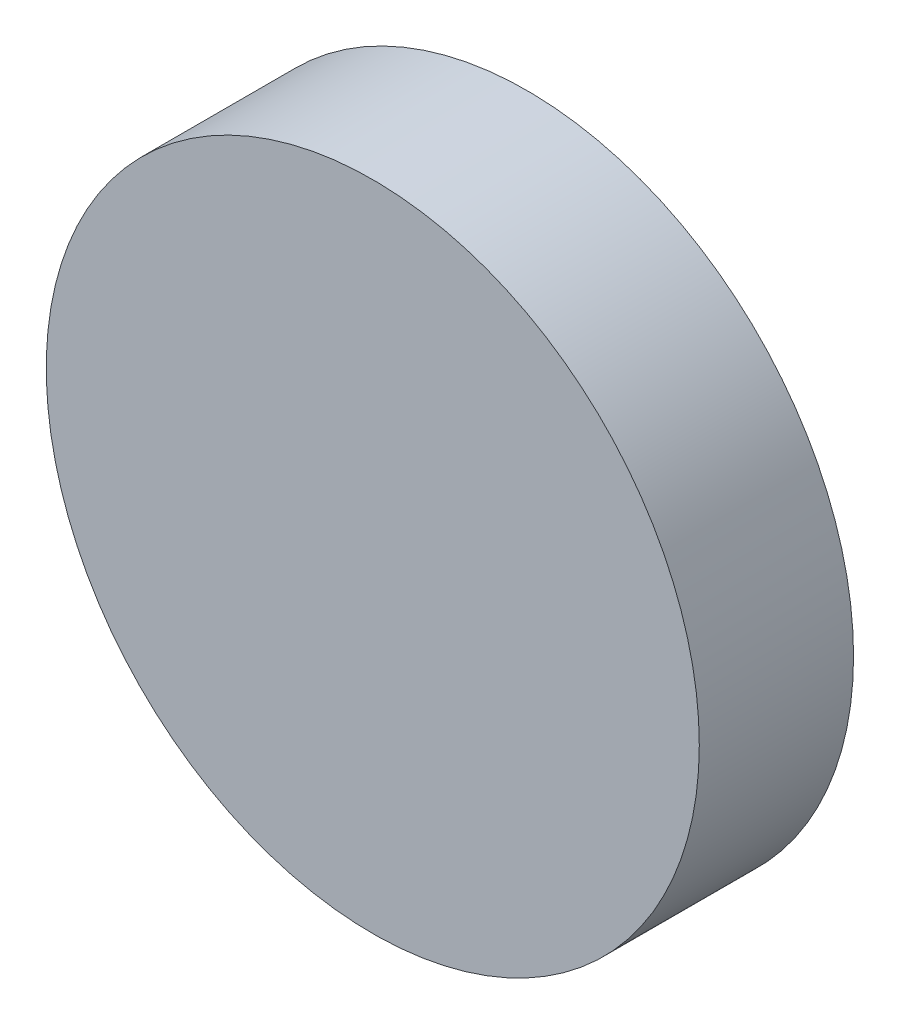
from build123d import *

# Parameters (mm, degrees)
SKETCH_1_R      = 6.35
EXTRUDE_1_DEPTH = 3


with BuildPart() as part:
    # 草图1 → 凸台-拉伸1 (new body)
    with BuildSketch(Plane.XY):
        Circle(SKETCH_1_R)
    extrude(amount=EXTRUDE_1_DEPTH)


solid = part.part
